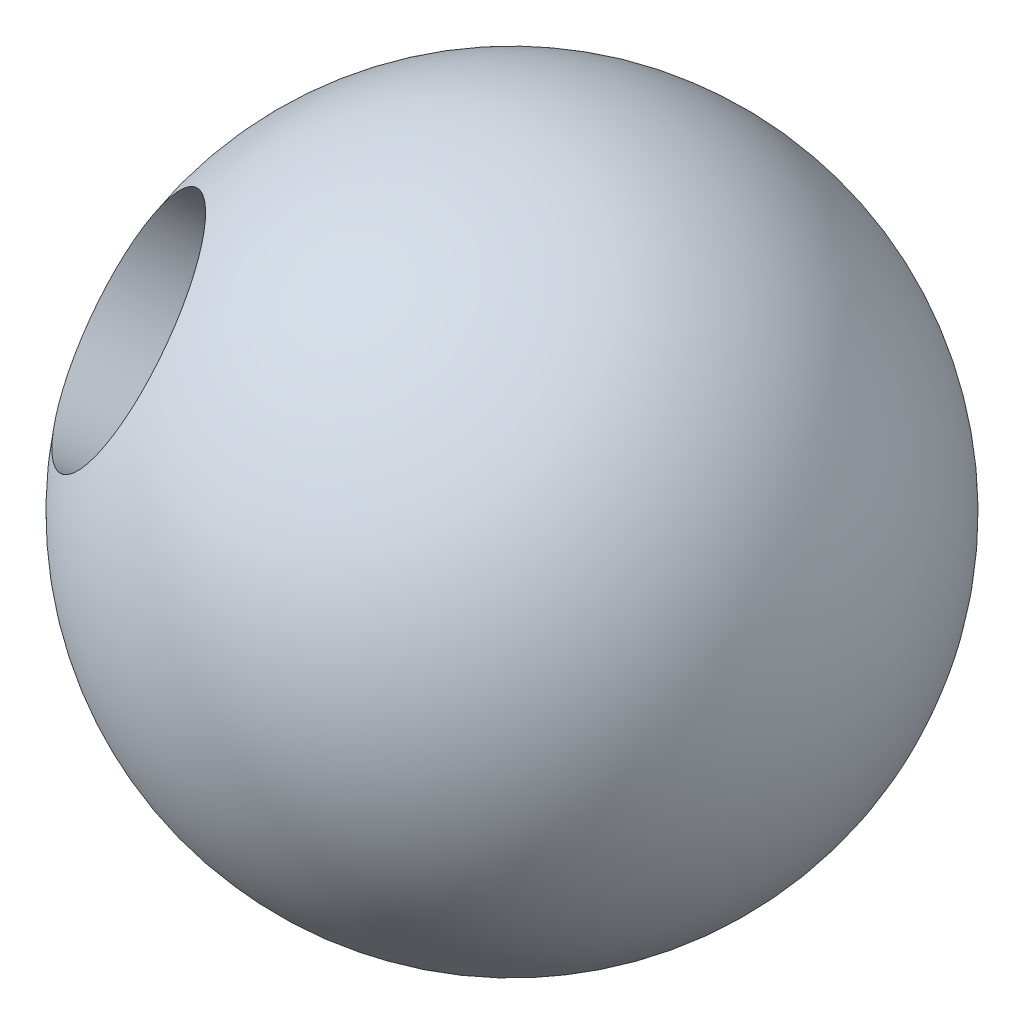
from build123d import *


with BuildPart() as part:
    # Sketch1 → Revolve1 (revolve)
    with BuildSketch(Plane.XY):
        with BuildLine():
            Line((0, 15), (0, -15))
            ThreePointArc((0, -15), (15, 0), (0, 15))
        make_face()
    revolve(axis=Axis((0, 15, 0), (0, -1, 0)))

    # Sketch2 → M12x1.75 Tapped Hole1 (revolve, cut)
    with BuildSketch(Plane(origin=(-9.617037072, 7.262212017, 8.931566188), x_dir=(0.050610565, -0.747524551, 0.662303266), z_dir=(0.765756783, 0.454761778, 0.454761778))):
        Polygon((0, 0), (0, 16.564389157), (5.1, 13.5), (5.1, 0), align=None)
    revolve(axis=Axis((-13.688249433, 10.336548437, 12.712595875), (0.641135805, -0.484147468, -0.595437746)), mode=Mode.SUBTRACT)


solid = part.part
